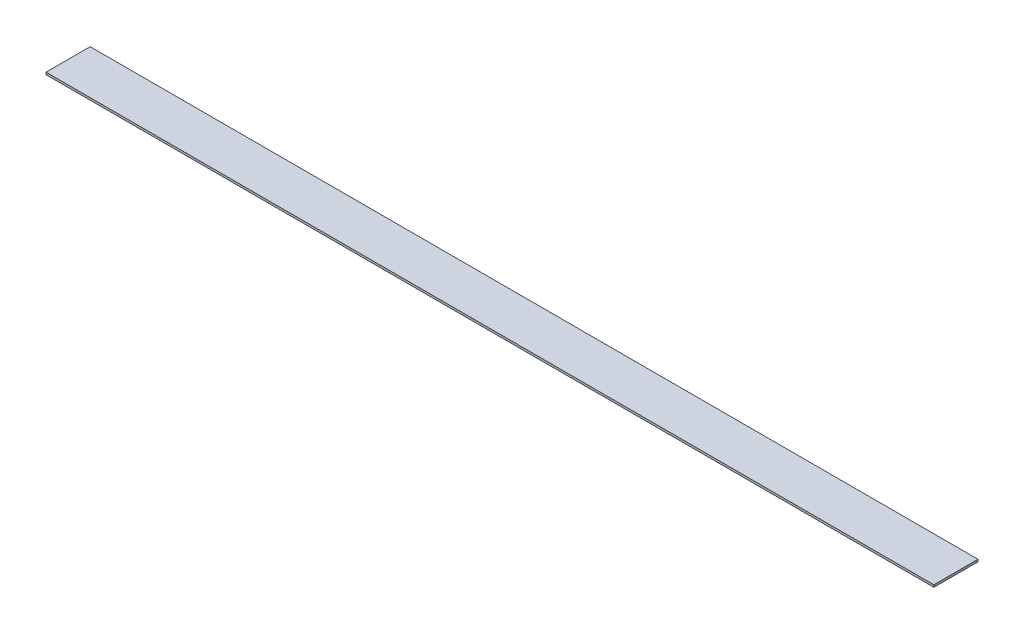
from build123d import *

# Parameters (mm, degrees)
SKETCH1_W           = 201.2
SKETCH1_H           = 10
BOSS_EXTRUDE1_DEPTH = 0.5


with BuildPart() as part:
    # Sketch1 → Boss-Extrude1 (new body)
    with BuildSketch(Plane(origin=(0, 0, 0), x_dir=(1, 0, 0), z_dir=(0, 1, 0))):
        with Locations((100.6, 5)):
            Rectangle(SKETCH1_W, SKETCH1_H)
    extrude(amount=BOSS_EXTRUDE1_DEPTH)


solid = part.part
